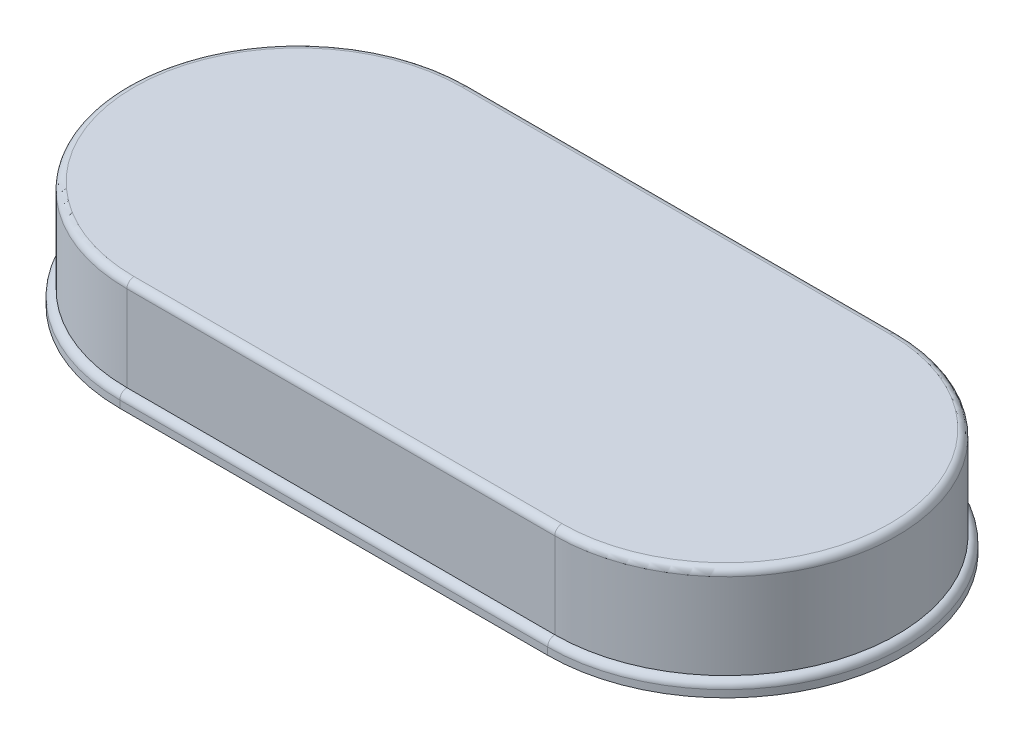
from build123d import *

# Parameters (mm, degrees)
BOSS_EXTRUDE1_DEPTH = 0.2
FILLET3_R           = 0.1
BOSS_EXTRUDE2_DEPTH = 1.3
FILLET4_R           = 0.1


with BuildPart() as part:
    # Sketch2 → Boss-Extrude1 (new body)
    with BuildSketch(Plane(origin=(0, 0, 0), x_dir=(1, 0, 0), z_dir=(0, 1, 0))):
        with BuildLine():
            Line((8.774632583, 14.872725815), (14.774632583, 14.872725815))
            ThreePointArc((14.774632583, 14.872725815), (17.274632583, 12.372725815), (14.774632583, 9.872725815))
            Line((14.774632583, 9.872725815), (8.774632583, 9.872725815))
            ThreePointArc((8.774632583, 9.872725815), (6.274632583, 12.372725815), (8.774632583, 14.872725815))
        make_face()
    extrude(amount=BOSS_EXTRUDE1_DEPTH)

    # Fillet3
    fillet3_edges = [part.edges().sort_by_distance(p)[0] for p in [
        (17.274632583, 0.2, -12.372725815),
        (11.774632583, 0.2, -14.872725815),
        (6.274632583, 0.2, -12.372725815),
        (11.774632583, 0.2, -9.872725815),
    ]]
    fillet(fillet3_edges, radius=FILLET3_R)

    # Sketch5 → Boss-Extrude2 (add)
    with BuildSketch(Plane(origin=(0, 0.2, 0), x_dir=(1, 0, 0), z_dir=(0, 1, 0))):
        with BuildLine():
            Line((8.774632583, 14.772725815), (14.774632583, 14.772725815))
            ThreePointArc((14.774632583, 14.772725815), (17.174632583, 12.372725815), (14.774632583, 9.972725815))
            Line((14.774632583, 9.972725815), (8.774632583, 9.972725815))
            ThreePointArc((8.774632583, 9.972725815), (6.374632583, 12.372725815), (8.774632583, 14.772725815))
        make_face()
    extrude(amount=BOSS_EXTRUDE2_DEPTH)

    # Fillet4
    fillet4_edges = [part.edges().sort_by_distance(p)[0] for p in [
        (6.374632583, 1.5, -12.372725815),
        (11.774632583, 1.5, -9.972725815),
        (17.174632583, 1.5, -12.372725815),
        (11.774632583, 1.5, -14.772725815),
    ]]
    fillet(fillet4_edges, radius=FILLET4_R)


solid = part.part
